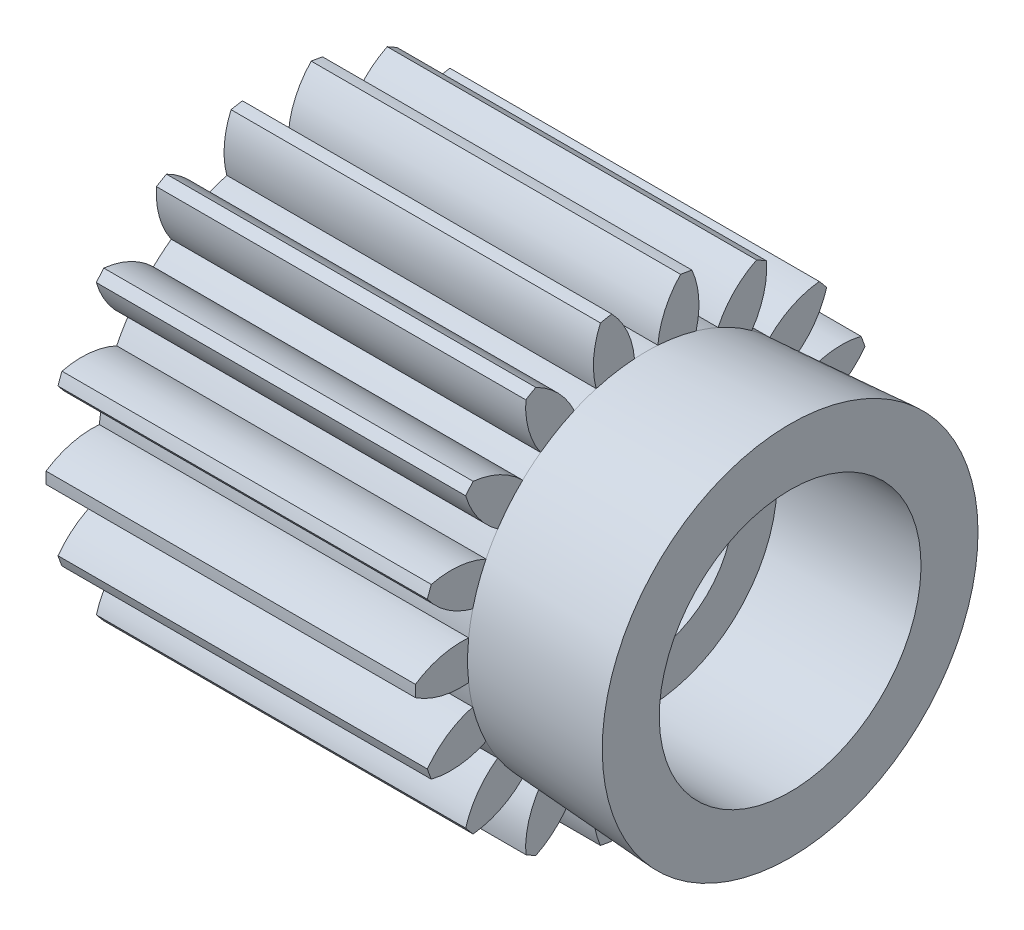
from build123d import *

# Parameters (mm, degrees)
BASPROSKE_W        = 12.7
BASPROSKE_H        = 7.9375
TOOTHCUT_DEPTH     = 17.949861725
TEETHCUTS_COUNT    = 18
TEETHCUTS_ANGLE    = 340
BORSKE_R           = 3
BORE_DEPTH         = 50.8000508
SKETCH2_R          = 4.5
CUT_EXTRUDE1_DEPTH = 4.95


with BuildPart() as part:
    # BasProSke → Base-Revolve (revolve)
    with BuildSketch(Plane(origin=(0, 0, 0), x_dir=(1, 0, 0), z_dir=(0, 1, 0)), mode=Mode.PRIVATE) as base_revolve_sk:
        with Locations((6.35, 3.96875)):
            Rectangle(BASPROSKE_W, BASPROSKE_H)
    revolve(base_revolve_sk.sketch.rotate(Axis((-10, 0, 0), (1, 0, 0)), 180), axis=Axis((-10, 0, 0), (1, 0, 0)))

    # TooCutSke → ToothCut (cut, through all)
    with BuildSketch(Plane(origin=(0, 0, 0), x_dir=(0, 0, -1), z_dir=(1, 0, 0))):
        with BuildLine():
            ThreePointArc((0.401805019, 6.127289689), (0, 6.14045), (-0.401805019, 6.127289689))
            ThreePointArc((-0.401805019, 6.127289689), (-0.651999955, 7.068698885), (-1.203877601, 7.87136933))
            ThreePointArc((-1.203877601, 7.87136933), (0, 7.9629), (1.203877601, 7.87136933))
            ThreePointArc((1.203877601, 7.87136933), (0.651999955, 7.068698885), (0.401805019, 6.127289689))
        make_face()
    toothcut = extrude(amount=TOOTHCUT_DEPTH, mode=Mode.SUBTRACT)

    # TeethCuts: ToothCut ×18 about axis
    teethcuts_axis = Axis((-10, 0, 0), (1, 0, 0))
    for i in range(1, TEETHCUTS_COUNT):
        add(toothcut.rotate(teethcuts_axis, i * TEETHCUTS_ANGLE / (TEETHCUTS_COUNT - 1)), mode=Mode.SUBTRACT)

    # BorSke → Bore (cut, symmetric)
    with BuildSketch(Plane(origin=(0, 0, 0), x_dir=(0, 0, -1), z_dir=(1, 0, 0))):
        with Locations(Location((0, 0, 0), (0, 0, 180))):
            Circle(BORSKE_R)
    extrude(amount=BORE_DEPTH, both=True, mode=Mode.SUBTRACT)

    # Sketch1 → Revolve1 (revolve)
    with BuildSketch(Plane.XY, mode=Mode.PRIVATE) as revolve1_sk:
        Polygon((12.7, 6.14045), (17.65, 6.46), (17.65, 4.46), (12.7, 4.46), align=None)
    revolve(revolve1_sk.sketch.rotate(Axis((12.7, 0, 0), (1, 0, 0)), 180), axis=Axis((12.7, 0, 0), (1, 0, 0)))

    # Sketch2 → Cut-Extrude1 (cut)
    with BuildSketch(Plane(origin=(17.65, 0, 0), x_dir=(0, 0, -1), z_dir=(1, 0, 0))):
        with Locations(Location((0, 0, 0), (0, 0, 90))):
            Circle(SKETCH2_R)
    extrude(amount=-CUT_EXTRUDE1_DEPTH, mode=Mode.SUBTRACT)


solid = part.part
